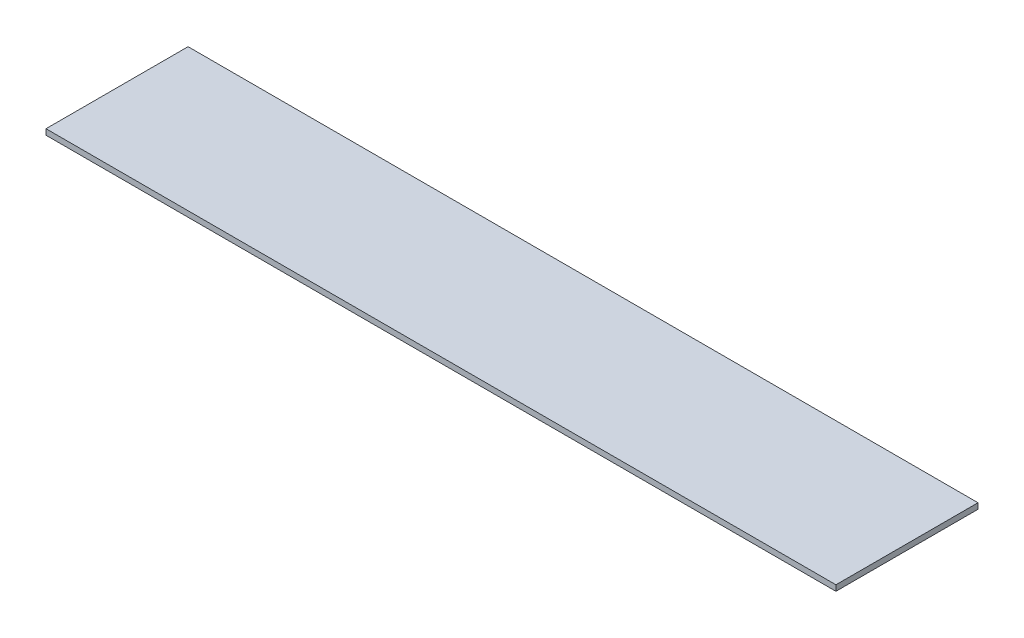
from build123d import *

# Parameters (mm, degrees)
SKETCH2_W           = 278
SKETCH2_H           = 50
BOSS_EXTRUDE1_DEPTH = 2


with BuildPart() as part:
    # Sketch2 → Boss-Extrude1 (new body)
    with BuildSketch(Plane(origin=(0, 0, 0), x_dir=(1, 0, 0), z_dir=(0, 1, 0))):
        with Locations((139, 25)):
            Rectangle(SKETCH2_W, SKETCH2_H)
    extrude(amount=BOSS_EXTRUDE1_DEPTH)


solid = part.part
